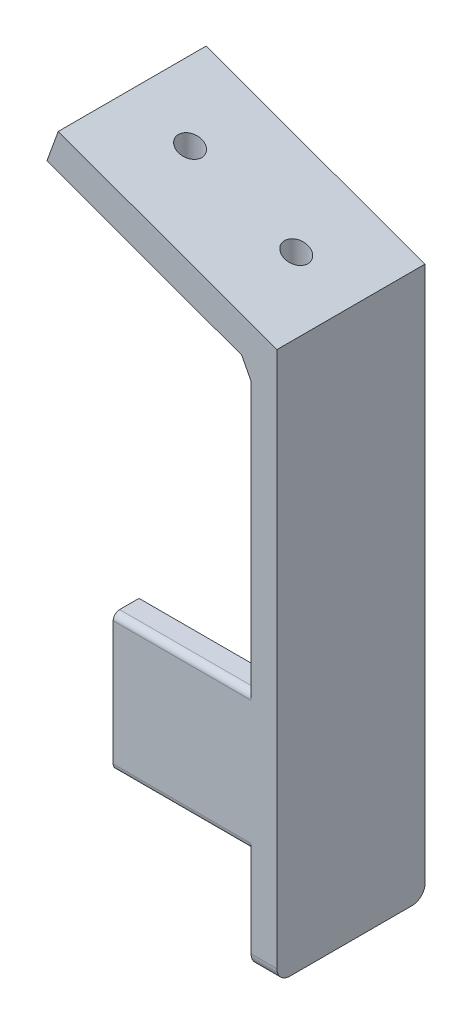
from build123d import *

# Parameters (mm, degrees)
ESQUISSE1_W             = 4
ESQUISSE1_H             = 85
BOSS_EXTRU_1_DEPTH      = 22.93
BOSS_EXTRU_5_DEPTH      = 22.9
ESQUISSE5_W             = 25.35
ESQUISSE5_H             = 21.181614094
BOSS_EXTRU_6_DEPTH      = 4
CONG_1_R                = 2
CONG_5_R                = 1
ESQUISSE9_R             = 1.8
ENL_V_MAT_EXTRU_1_DEPTH = 58
BOSS_EXTRU_8_DEPTH      = 1
BOSS_EXTRU_9_DEPTH      = 22.9


with BuildPart() as part:
    # Esquisse1 → Boss.-Extru.1 (new body)
    with BuildSketch(Plane.XY):
        with Locations((-2, -15.95097561)):
            Rectangle(ESQUISSE1_W, ESQUISSE1_H)
    extrude(amount=BOSS_EXTRU_1_DEPTH)

    # Esquisse2 → Boss.-Extru.5 (add)
    with BuildSketch(Plane.XY.offset(22.93)):
        Polygon((-33.850627534, 38.869645224), (0, 26.54902439), (0, 22.54902439), (-4, 22.54902439), (-35.604113867, 34.051981118), align=None)
    extrude(amount=-BOSS_EXTRU_5_DEPTH)

    # Esquisse5 → Boss.-Extru.6 (add)
    with BuildSketch(Plane.XY.offset(22.93)):
        with Locations((-12.675, -32.061782657)):
            Rectangle(ESQUISSE5_W, ESQUISSE5_H)
    extrude(amount=-BOSS_EXTRU_6_DEPTH)

    # Congé1
    cong_1_edges = [part.edges().sort_by_distance(p)[0] for p in [
        (-2, -58.45097561, 22.93),
        (-2, -58.45097561, 0),
    ]]
    fillet(cong_1_edges, radius=CONG_1_R)

    # Congé5
    cong_5_edges = [part.edges().sort_by_distance(p)[0] for p in [
        (-14.675, -21.47097561, 22.93),
        (-14.675, -42.652589704, 22.93),
    ]]
    fillet(cong_5_edges, radius=CONG_5_R)

    # Esquisse9 → Enlèv. mat.-Extru.1 (cut)
    with BuildSketch(Plane(origin=(0, 0, 0), x_dir=(1, 0, 0), z_dir=(0, 1, 0))):
        with Locations((-24.9342899, -11.439091382)):
            Circle(ESQUISSE9_R)
        with Locations((-8.483694977, -11.459545691)):
            Circle(ESQUISSE9_R)
    extrude(amount=ENL_V_MAT_EXTRU_1_DEPTH, mode=Mode.SUBTRACT)

    # Esquisse10 → Boss.-Extru.8 (add)
    with BuildSketch(Plane.ZY.offset(4)):
        with BuildLine():
            Line((10.166030362, 18.2390183), (11.166631323, 18.2390183))
            add(Edge.make_bspline(
                [(11.166631323, 18.2390183), (11.233404364, 18.238796034), (11.361615999, 18.238369259), (11.545292099, 18.235989598), (11.712187952, 18.22916909), (11.862216294, 18.223299685), (11.995374373, 18.212596912), (12.112070502, 18.202367416), (12.211767213, 18.188976472), (12.272118429, 18.176540153), (12.299443823, 18.170909326)],
                knots=[0, 0, 0, 0, 0.000200323, 0.000384642, 0.000551017, 0.000701421, 0.00083501, 0.000951717, 0.001052854, 0.001136534, 0.001136534, 0.001136534, 0.001136534], degree=3))
            add(Edge.make_bspline(
                [(12.299443823, 18.170909326), (12.336024715, 18.161871089), (12.408406128, 18.143987427), (12.512620508, 18.106187997), (12.611926685, 18.062445676), (12.705912149, 18.011068933), (12.794106136, 17.951676391), (12.877418009, 17.885293359), (12.956225814, 17.812283065), (13.027342428, 17.73080472), (13.094398216, 17.645323991), (13.150953397, 17.552890053), (13.199705511, 17.456230728), (13.238520535, 17.354362988), (13.269774783, 17.248274743), (13.291812268, 17.137005033), (13.30502825, 17.021060783), (13.306373758, 16.941978056), (13.307056003, 16.901878877)],
                knots=[0, 0, 0, 0, 0.000112973, 0.000223535, 0.000332046, 0.000438282, 0.0005444, 0.000650613, 0.000757615, 0.000866163, 0.000974744, 0.001083144, 0.001190647, 0.001299089, 0.001409706, 0.001522064, 0.001638977, 0.001759236, 0.001759236, 0.001759236, 0.001759236], degree=3))
            add(Edge.make_bspline(
                [(13.307056003, 16.901878877), (13.304957434, 16.835257299), (13.300862583, 16.705261345), (13.262683863, 16.516602943), (13.200145978, 16.340618207), (13.113969851, 16.177528725), (13.004227743, 16.030513517), (12.872335184, 15.901384295), (12.718218596, 15.793327277), (12.574748145, 15.718394699), (12.448013574, 15.67040483), (12.34368027, 15.636638603), (12.229870302, 15.610550081), (12.10767411, 15.587178464), (11.976583173, 15.569533186), (11.836911688, 15.55660948), (11.688560043, 15.548532268), (11.586647087, 15.547329403), (11.534219464, 15.546710608)],
                knots=[0, 0, 0, 0, 0.000199681, 0.000389629, 0.000574641, 0.000758347, 0.00094084, 0.00112287, 0.00130963, 0.001503603, 0.001606651, 0.001715936, 0.001832303, 0.001956651, 0.002089094, 0.002228924, 0.002377378, 0.002534658, 0.002534658, 0.002534658, 0.002534658], degree=3))
            Line((11.534219464, 15.546710608), (13.371158567, 13.2390183))
            Line((13.371158567, 13.2390183), (12.816270746, 13.2390183))
            Line((12.816270746, 13.2390183), (10.979331644, 15.546710608))
            Line((10.979331644, 15.546710608), (10.61474831, 15.546710608))
            Line((10.61474831, 15.546710608), (10.61474831, 13.2390183))
            Line((10.61474831, 13.2390183), (10.166030362, 13.2390183))
            Line((10.166030362, 13.2390183), (10.166030362, 18.2390183))
        make_face()
        with BuildLine():
            Line((10.61474831, 17.726197787), (10.61474831, 16.05953112))
            Line((10.61474831, 16.05953112), (11.530213054, 16.052519902))
            add(Edge.make_bspline(
                [(11.530213054, 16.052519902), (11.572955967, 16.052500993), (11.655803905, 16.052464341), (11.775661998, 16.058169736), (11.887262158, 16.06466019), (11.990177518, 16.074587827), (12.084454054, 16.087382215), (12.170044644, 16.103386478), (12.247089004, 16.122032282), (12.336944059, 16.150891747), (12.437281961, 16.196614631), (12.546326904, 16.263136772), (12.639187386, 16.346806942), (12.717641475, 16.442483308), (12.78068352, 16.547677949), (12.825129312, 16.661129905), (12.853332801, 16.779975045), (12.856659294, 16.861658056), (12.858338054, 16.902880479)],
                knots=[0, 0, 0, 0, 0.000128209, 0.000248506, 0.000359904, 0.000463555, 0.000558601, 0.000645233, 0.000724669, 0.000796254, 0.000928055, 0.001054503, 0.00117794, 0.001301056, 0.001424562, 0.001544156, 0.0016654, 0.001788926, 0.001788926, 0.001788926, 0.001788926], degree=3))
            add(Edge.make_bspline(
                [(12.858338054, 16.902880479), (12.856620738, 16.94308987), (12.853217645, 17.022770211), (12.82543369, 17.139421512), (12.778448859, 17.249517155), (12.715131376, 17.352609276), (12.637989726, 17.446188899), (12.547535708, 17.52625626), (12.446242572, 17.592326924), (12.351569432, 17.634547468), (12.266949128, 17.660432973), (12.193478185, 17.678648921), (12.110461789, 17.693283876), (12.017496848, 17.705009678), (11.914980232, 17.715088169), (11.802393588, 17.721876425), (11.680483902, 17.725896231), (11.595988286, 17.726094929), (11.55224831, 17.726197787)],
                knots=[0, 0, 0, 0, 0.00012053, 0.000238846, 0.000357345, 0.000478278, 0.000600621, 0.000719816, 0.000839275, 0.000962126, 0.001029286, 0.001104593, 0.001189072, 0.001282, 0.00138565, 0.001498049, 0.00162031, 0.001751524, 0.001751524, 0.001751524, 0.001751524], degree=3))
            Line((11.55224831, 17.726197787), (10.61474831, 17.726197787))
        make_face(mode=Mode.SUBTRACT)
    extrude(amount=BOSS_EXTRU_8_DEPTH)

    # Esquisse11 → Boss.-Extru.9 (add)
    with BuildSketch(Plane.XY.offset(22.93)):
        Polygon((-5.452843765, 23.077816276), (-4, 20.298440223), (-0.659211444, 23.077816276), align=None)
    extrude(amount=-BOSS_EXTRU_9_DEPTH)


solid = part.part
